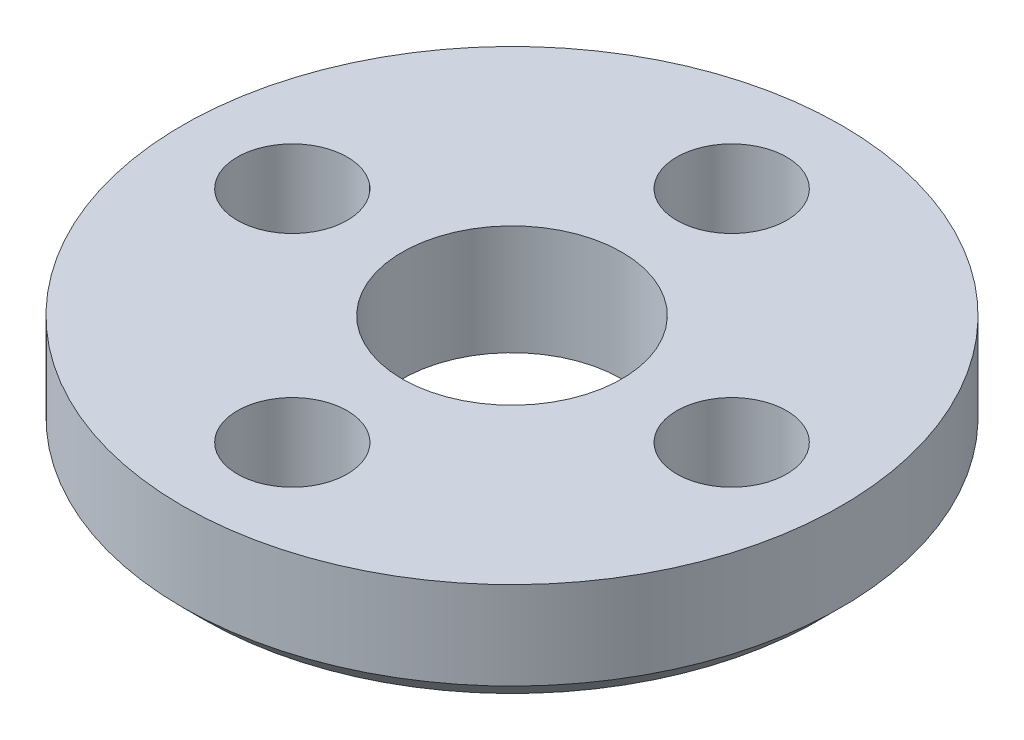
from build123d import *

# Parameters (mm, degrees)
SKETCH1_R           = 15
SKETCH1_R_2         = 5
BOSS_EXTRUDE1_DEPTH = 5
SKETCH1_3_R         = 2.5
CUT_EXTRUDE1_DEPTH  = 5
CIRPATTERN1_COUNT   = 4
CHAMFER1_SIZE       = 1


with BuildPart() as part:
    # Sketch1 → Boss-Extrude1 (new body)
    with BuildSketch(Plane(origin=(0, 0, 0), x_dir=(1, 0, 0), z_dir=(0, 1, 0))):
        Circle(SKETCH1_R)
        Circle(SKETCH1_R_2, mode=Mode.SUBTRACT)
    extrude(amount=-BOSS_EXTRUDE1_DEPTH)

    # Sketch1_3 → Cut-Extrude1 (cut)
    with BuildSketch(Plane(origin=(0, 0, 0), x_dir=(1, 0, 0), z_dir=(0, 1, 0))):
        with Locations((0, 10)):
            Circle(SKETCH1_3_R)
    cut_extrude1 = extrude(amount=-CUT_EXTRUDE1_DEPTH, mode=Mode.SUBTRACT)

    # CirPattern1: Cut-Extrude1 ×4 about axis
    cirpattern1_axis = Axis((0, -5, 0), (0, 1, 0))
    for i in range(1, CIRPATTERN1_COUNT):
        add(cut_extrude1.rotate(cirpattern1_axis, i * 360 / CIRPATTERN1_COUNT), mode=Mode.SUBTRACT)

    # Chamfer1
    chamfer1_edges = [part.edges().sort_by_distance(p)[0] for p in [
        (-15, -5, 0),
    ]]
    chamfer(chamfer1_edges, length=CHAMFER1_SIZE)


solid = part.part
